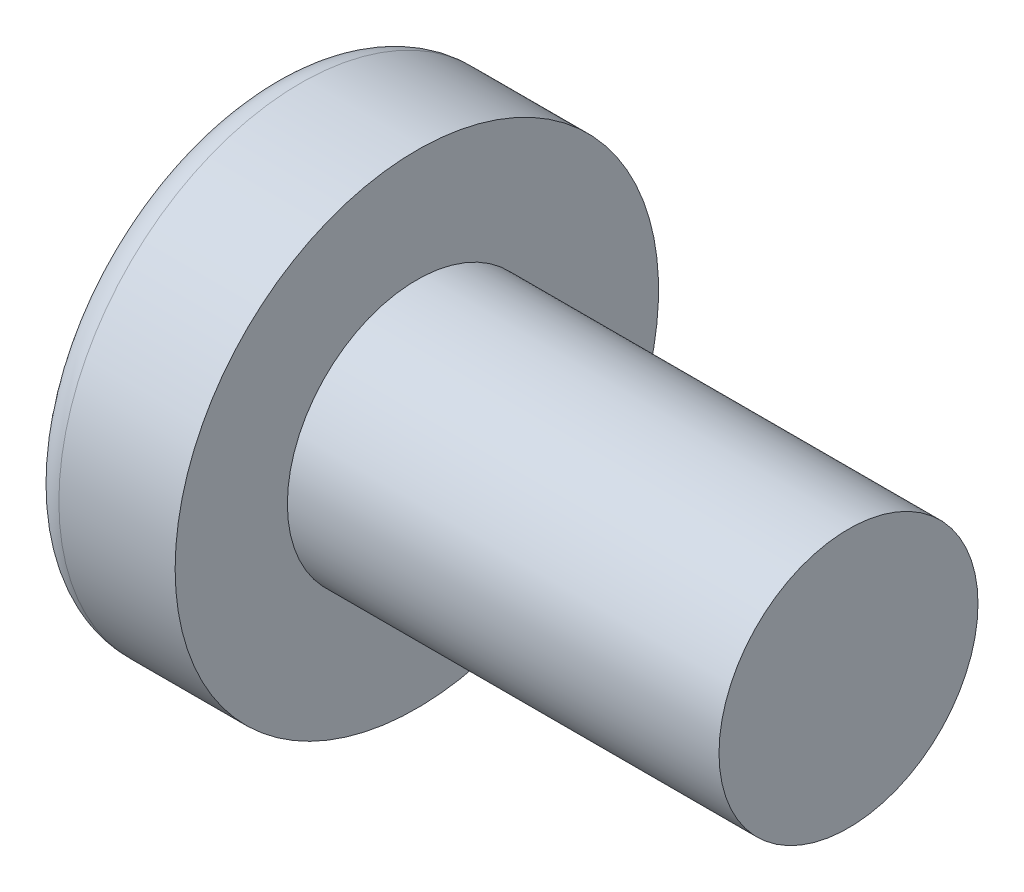
from build123d import *

# Parameters (mm, degrees)
SKETCH3_W         = 0.74
SKETCH3_H         = 2.9
SKETCH4_W         = 0.37
SKETCH4_H         = 0.37
CIRPATTERN1_COUNT = 2
CIRPATTERN1_ANGLE = 90


with BuildPart() as part:
    # BodySke → Base-Revolve (revolve)
    with BuildSketch(Plane.XY):
        with BuildLine():
            Line((2.4, 1.5), (2.4, 2.8))
            Line((2.4, 2.8), (1.053355856, 2.8))
            ThreePointArc((1.053355856, 2.8), (0.878072834, 2.754445324), (0.747150707, 2.629310345))
            ThreePointArc((0.747150707, 2.629310345), (0.190413403, 1.366702882), (0, 0))
            Line((0, 0), (7.4, 0))
            Line((7.4, 0), (7.4, 1.5))
            Line((7.4, 1.5), (2.4, 1.5))
        make_face()
    revolve(axis=Axis((-25.4, 0, 0), (1, 0, 0)))

    # Sketch3 → Cut-Loft1 section 0
    with BuildSketch(Plane(origin=(0, 0, 0), x_dir=(0, 0, -1), z_dir=(1, 0, 0))):
        Rectangle(SKETCH3_W, SKETCH3_H)
    # Sketch4 → Cut-Loft1 section 1
    with BuildSketch(Plane(origin=(1.76, 0, 0), x_dir=(0, 0, -1), z_dir=(1, 0, 0))):
        Rectangle(SKETCH4_W, SKETCH4_H)
    cut_loft1 = loft(mode=Mode.SUBTRACT)

    # CirPattern1: Cut-Loft1 ×2 about axis
    cirpattern1_axis = Axis((0, 0, 0), (1, 0, 0))
    for i in range(1, CIRPATTERN1_COUNT):
        add(cut_loft1.rotate(cirpattern1_axis, i * CIRPATTERN1_ANGLE / (CIRPATTERN1_COUNT - 1)), mode=Mode.SUBTRACT)


solid = part.part
